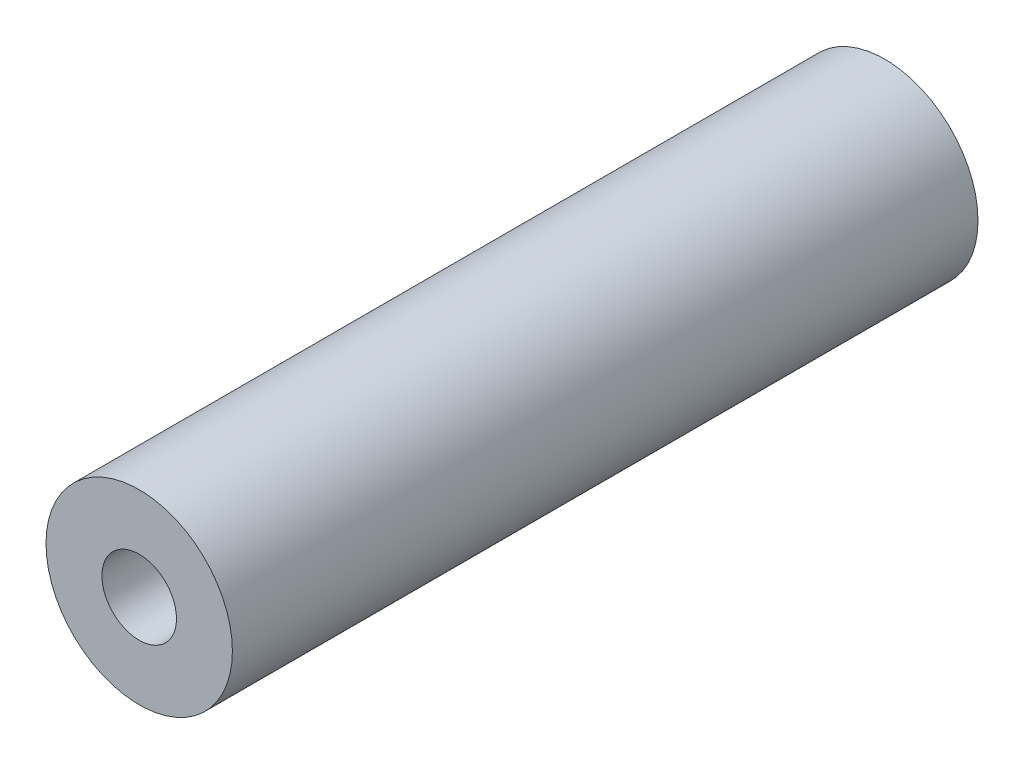
from build123d import *

# Parameters (mm, degrees)
SKETCH_1_R      = 5
SKETCH_1_R_2    = 2
EXTRUDE_1_DEPTH = 40


with BuildPart() as part:
    # 草圖1 → 填料-伸長1 (new body)
    with BuildSketch(Plane.XY):
        Circle(SKETCH_1_R)
        Circle(SKETCH_1_R_2, mode=Mode.SUBTRACT)
    extrude(amount=EXTRUDE_1_DEPTH)


solid = part.part
